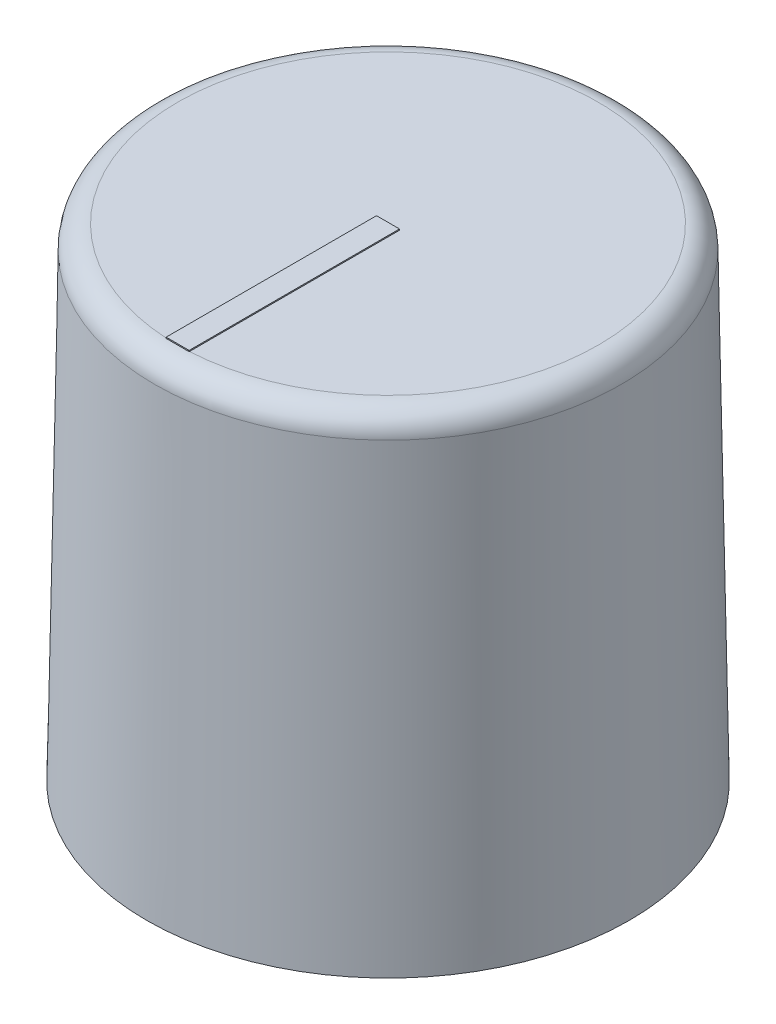
from build123d import *

# Parameters (mm, degrees)
SKETCH1_R           = 10.5
BOSS_EXTRUDE1_DEPTH = 21
BOSS_EXTRUDE1_TAPER = 1
SKETCH2_R           = 9
CUT_EXTRUDE1_DEPTH  = 20
FILLET1_R           = 1
SKETCH3_W           = 1
SKETCH3_H           = 9.150746373
BOSS_EXTRUDE2_DEPTH = 0.05


with BuildPart() as part:
    # Sketch1 → Boss-Extrude1 (new body)
    with BuildSketch(Plane(origin=(0, 0, 0), x_dir=(1, 0, 0), z_dir=(0, 1, 0))):
        Circle(SKETCH1_R)
    extrude(amount=BOSS_EXTRUDE1_DEPTH, taper=BOSS_EXTRUDE1_TAPER)

    # Sketch2 → Cut-Extrude1 (cut)
    with BuildSketch(Plane.XZ):
        Circle(SKETCH2_R)
    extrude(amount=-CUT_EXTRUDE1_DEPTH, mode=Mode.SUBTRACT)

    # Fillet1
    fillet1_edges = [part.edges().sort_by_distance(p)[0] for p in [
        (-10.133443637, 21, 0),
    ]]
    fillet(fillet1_edges, radius=FILLET1_R)

    # Sketch3 → Boss-Extrude2 (add)
    with BuildSketch(Plane(origin=(0, 21, 0), x_dir=(1, 0, 0), z_dir=(0, 1, 0))):
        with Locations((0, -4.575373187)):
            Rectangle(SKETCH3_W, SKETCH3_H)
    extrude(amount=BOSS_EXTRUDE2_DEPTH)


solid = part.part
